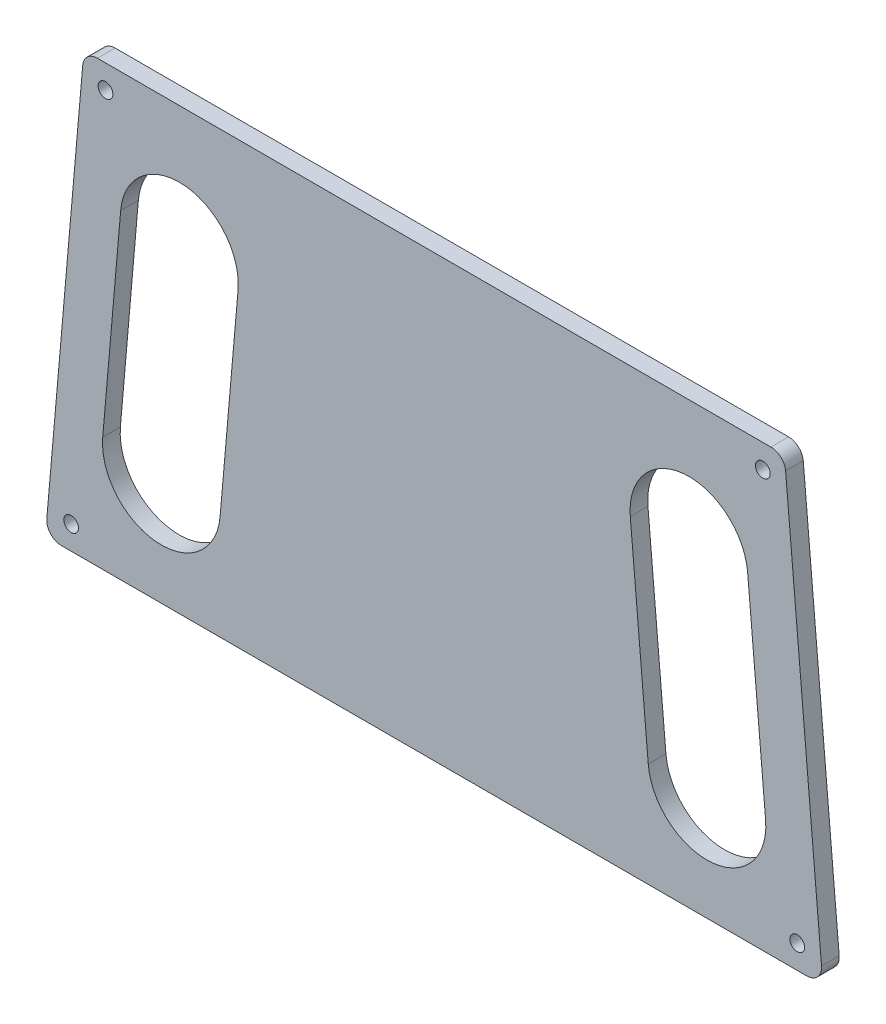
from build123d import *

# Parameters (mm, degrees)
SKETCH1_R           = 1.25
BOSS_EXTRUDE1_DEPTH = 3


with BuildPart() as part:
    # Sketch1 → Boss-Extrude1 (new body)
    with BuildSketch(Plane.XY.offset(11)):
        with BuildLine():
            Line((57.172491377, 74.714602367), (-57.172491341, 74.714602367))
            ThreePointArc((-57.172491341, 74.714602367), (-58.861466857, 74.05779571), (-59.662978082, 72.432491728))
            Line((-59.662978082, 72.432491728), (-65.762215507, 2.717889374))
            ThreePointArc((-65.762215507, 2.717889374), (-65.1149221, 0.811024486), (-63.271728747, 0))
            Line((-63.271728747, 0), (63.271728783, 0))
            ThreePointArc((63.271728783, 0), (65.114922137, 0.811024486), (65.762215543, 2.717889374))
            Line((65.762215543, 2.717889374), (59.662978119, 72.432491728))
            ThreePointArc((59.662978119, 72.432491728), (58.861466894, 74.05779571), (57.172491377, 74.714602367))
        make_face()
        with Locations((55.797994598, 70.714602357)):
            Circle(SKETCH1_R, mode=Mode.SUBTRACT)
        with Locations((-61.634765996, 4)):
            Circle(SKETCH1_R, mode=Mode.SUBTRACT)
        with Locations((-55.797994598, 70.714602357)):
            Circle(SKETCH1_R, mode=Mode.SUBTRACT)
        with Locations((61.634765996, 4)):
            Circle(SKETCH1_R, mode=Mode.SUBTRACT)
        with BuildLine():
            Line((53.217813713, 54.311351811), (56.268264715, 19.444537378))
            ThreePointArc((56.268264715, 19.444537378), (47.177875152, 8.611032956), (36.34437073, 17.701422518))
            Line((36.34437073, 17.701422518), (33.293919727, 52.56823695))
            ThreePointArc((33.293919727, 52.56823695), (42.38430929, 63.401741373), (53.217813713, 54.311351811))
        make_face(mode=Mode.SUBTRACT)
        with BuildLine():
            Line((-33.293919727, 52.56823695), (-36.34437073, 17.701422518))
            ThreePointArc((-36.34437073, 17.701422518), (-47.17787515, 8.611032957), (-56.268264712, 19.444537376))
            Line((-56.268264712, 19.444537376), (-53.217813716, 54.311351809))
            ThreePointArc((-53.217813716, 54.311351809), (-42.384309292, 63.401741375), (-33.293919727, 52.56823695))
        make_face(mode=Mode.SUBTRACT)
    extrude(amount=-BOSS_EXTRUDE1_DEPTH)


solid = part.part
